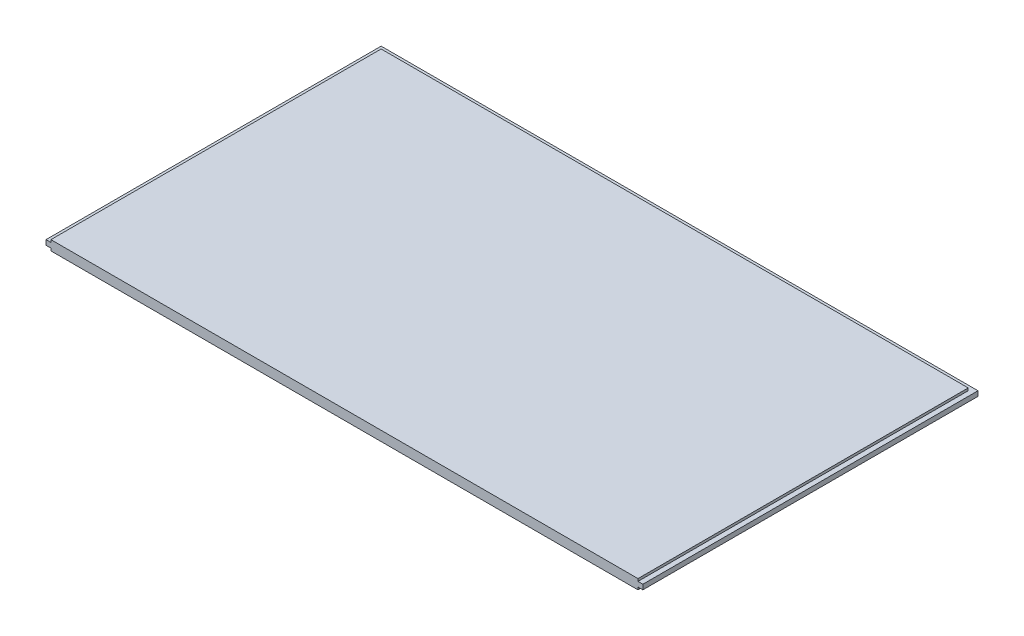
from build123d import *

# Parameters (mm, degrees)
SKETCH1_W           = 774.7
SKETCH1_H           = 434.975
BOSS_EXTRUDE1_DEPTH = 12.7
SKETCH2_W           = 6.35
SKETCH2_H           = 3.175
CUT_EXTRUDE1_DEPTH  = 775.7
SKETCH3_W           = 6.35
SKETCH3_H           = 3.175
CUT_EXTRUDE2_DEPTH  = 435.975


with BuildPart() as part:
    # Sketch1 → Boss-Extrude1 (new body)
    with BuildSketch(Plane(origin=(0, 0, 0), x_dir=(1, 0, 0), z_dir=(0, 1, 0))):
        with Locations((43.291693811, -51.808346906)):
            Rectangle(SKETCH1_W, SKETCH1_H)
    extrude(amount=BOSS_EXTRUDE1_DEPTH)

    # Sketch2 → Cut-Extrude1 (cut, through all)
    with BuildSketch(Plane.ZY.offset(344.058306189)):
        with Locations((-162.504153094, 11.1125)):
            Rectangle(SKETCH2_W, SKETCH2_H)
        with Locations((-162.504153094, 1.5875)):
            Rectangle(SKETCH2_W, SKETCH2_H)
    extrude(amount=-CUT_EXTRUDE1_DEPTH, mode=Mode.SUBTRACT)

    # Sketch3 → Cut-Extrude2 (cut, through all)
    with BuildSketch(Plane.XY.offset(269.295846906)):
        with Locations((-340.883306189, 11.1125)):
            Rectangle(SKETCH3_W, SKETCH3_H)
        with Locations((-340.883306189, 1.5875)):
            Rectangle(SKETCH3_W, SKETCH3_H)
        with Locations((427.466693811, 1.5875)):
            Rectangle(SKETCH3_W, SKETCH3_H)
        with Locations((427.466693811, 11.1125)):
            Rectangle(SKETCH3_W, SKETCH3_H)
    extrude(amount=-CUT_EXTRUDE2_DEPTH, mode=Mode.SUBTRACT)


solid = part.part
